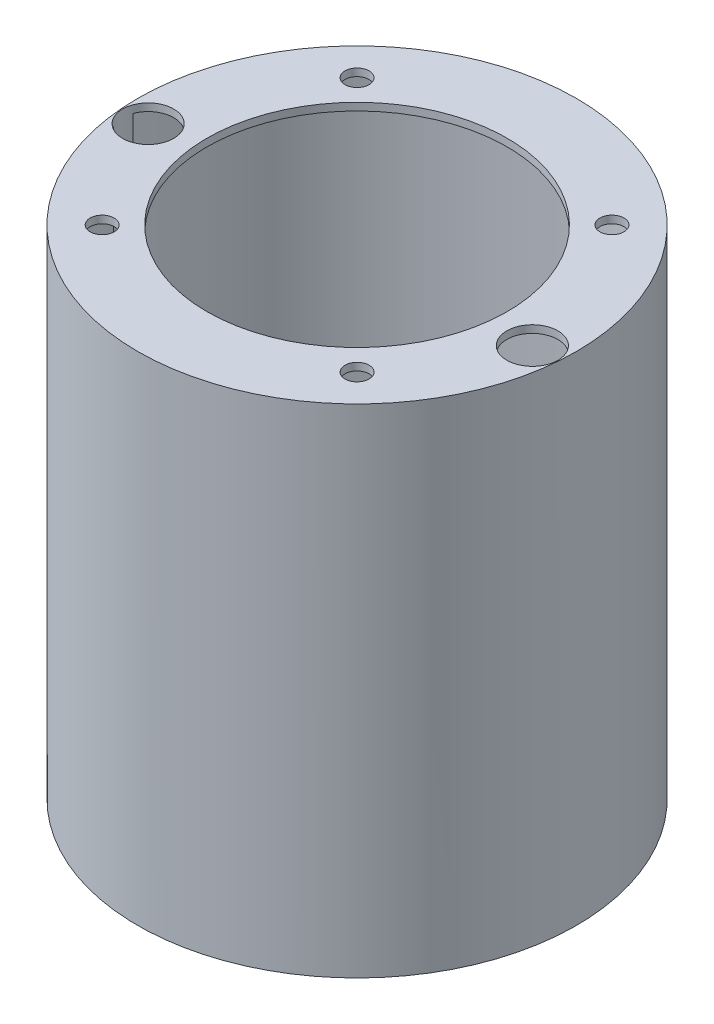
from build123d import *

# Parameters (mm, degrees)
SKETCH1_R                            = 92.71
SKETCH1_R_2                          = 63.5
TOP_RING_DEPTH                       = 3.175
SKETCH2_R                            = 92.71
SKETCH2_R_2                          = 91.44
CYLINDRICAL_EXTENSTION_DEPTH         = 207.01
SKETCH3_R                            = 10.795
NOSE_CONE_EJECTION_CHARGE_HOLE_DEPTH = 210.185
SKETCH4_R                            = 5.08
CUT_EXTRUDE1_DEPTH                   = 3.175


with BuildPart() as part:
    # Sketch1 → Top Ring (new body)
    with BuildSketch(Plane(origin=(0, 0, 0), x_dir=(1, 0, 0), z_dir=(0, 1, 0))):
        Circle(SKETCH1_R)
        Circle(SKETCH1_R_2, mode=Mode.SUBTRACT)
    extrude(amount=TOP_RING_DEPTH)

    # Sketch2 → Cylindrical extenstion (add)
    with BuildSketch(Plane.XZ):
        Circle(SKETCH2_R)
        Circle(SKETCH2_R_2, mode=Mode.SUBTRACT)
    extrude(amount=CYLINDRICAL_EXTENSTION_DEPTH)

    # Sketch3 → Nose Cone Ejection Charge Hole (cut)
    with BuildSketch(Plane(origin=(0, 3.175, 0), x_dir=(1, 0, 0), z_dir=(0, 1, 0))):
        with Locations((81.223738514, -7.106156329)):
            Circle(SKETCH3_R)
    nose_cone_ejection_charge_hole = extrude(amount=-NOSE_CONE_EJECTION_CHARGE_HOLE_DEPTH, mode=Mode.SUBTRACT)

    # Nose Cone Ejection Charge Mirror: Nose Cone Ejection Charge Hole across plane
    add(nose_cone_ejection_charge_hole.mirror(Plane(origin=(0, 0, 0), x_dir=(0, 0, 1), z_dir=(1, 0, 0))), mode=Mode.SUBTRACT)

    # Sketch4 → Cut-Extrude1 (cut)
    with BuildSketch(Plane(origin=(0, 3.175, 0), x_dir=(1, 0, 0), z_dir=(0, 1, 0))):
        with Locations((53.881536726, -53.881536726)):
            Circle(SKETCH4_R)
        with Locations((-53.881536726, -53.881536726)):
            Circle(SKETCH4_R)
        with Locations((-53.881536726, 53.881536726)):
            Circle(SKETCH4_R)
        with Locations((53.881536726, 53.881536726)):
            Circle(SKETCH4_R)
    extrude(amount=-CUT_EXTRUDE1_DEPTH, mode=Mode.SUBTRACT)


solid = part.part
